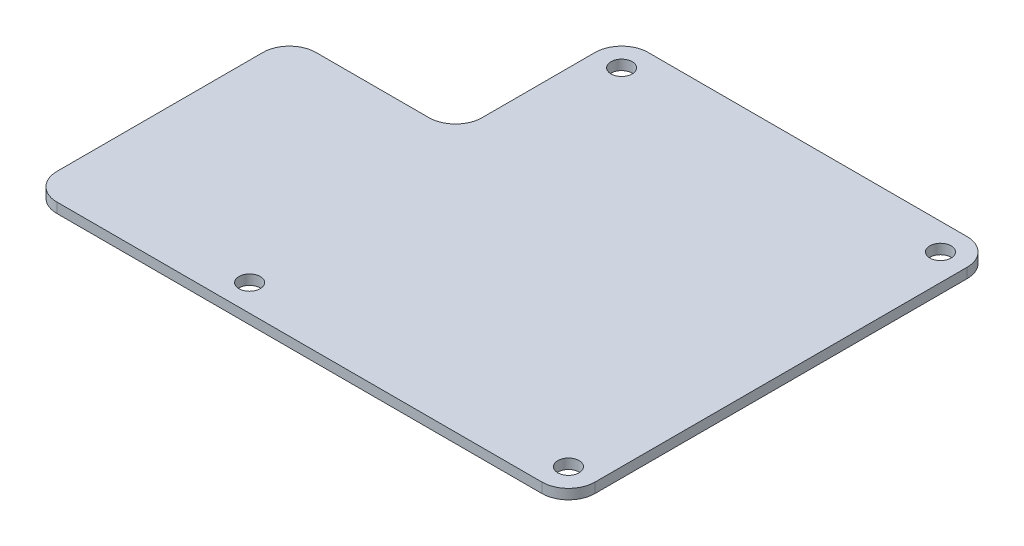
from build123d import *

# Parameters (mm, degrees)
SKETCH1_R           = 1.6
BOSS_EXTRUDE1_DEPTH = 1.5


with BuildPart() as part:
    # Sketch1 → Boss-Extrude1 (new body)
    with BuildSketch(Plane(origin=(0, 0, 0), x_dir=(1, 0, 0), z_dir=(0, 1, 0))):
        with BuildLine():
            Line((-8, 35), (-25, 35))
            ThreePointArc((-25, 35), (-27.828427125, 33.828427125), (-29, 31))
            Line((-29, 31), (-29, 0))
            ThreePointArc((-29, 0), (-27.828427125, -2.828427125), (-25, -4))
            Line((-25, -4), (-8, -4))
            Line((-8, -4), (48, -4))
            ThreePointArc((48, -4), (50.828427125, -2.828427125), (52, 0))
            Line((52, 0), (52, 56))
            ThreePointArc((52, 56), (50.828427125, 58.828427125), (48, 60))
            Line((48, 60), (0, 60))
            ThreePointArc((0, 60), (-2.828427125, 58.828427125), (-4, 56))
            Line((-4, 56), (-4, 39))
            ThreePointArc((-4, 39), (-5.171572875, 36.171572875), (-8, 35))
        make_face()
        with Locations((0, 56)):
            Circle(SKETCH1_R, mode=Mode.SUBTRACT)
        with Locations((48, 56)):
            Circle(SKETCH1_R, mode=Mode.SUBTRACT)
        with Locations((48, 0)):
            Circle(SKETCH1_R, mode=Mode.SUBTRACT)
        Circle(SKETCH1_R, mode=Mode.SUBTRACT)
    extrude(amount=BOSS_EXTRUDE1_DEPTH)


solid = part.part
